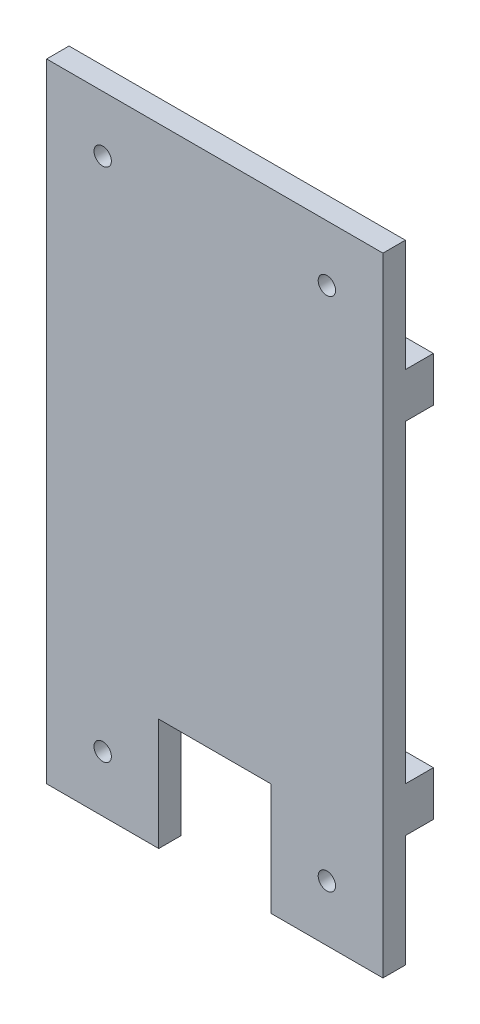
from build123d import *

# Parameters (mm, degrees)
SKETCH1_R           = 1.55
BOSS_EXTRUDE1_DEPTH = 4
SKETCH2_W           = 60
SKETCH2_H           = 8
BOSS_EXTRUDE2_DEPTH = 5


with BuildPart() as part:
    # Sketch1 → Boss-Extrude1 (new body)
    with BuildSketch(Plane.XY):
        Polygon((-30, 56), (-30, -56), (-10, -56), (-10, -36), (10, -36), (10, -56), (30, -56), (30, 56), align=None)
        with Locations((-20, -46)):
            Circle(SKETCH1_R, mode=Mode.SUBTRACT)
        with Locations((20, -46)):
            Circle(SKETCH1_R, mode=Mode.SUBTRACT)
        with Locations((-20, 46)):
            Circle(SKETCH1_R, mode=Mode.SUBTRACT)
        with Locations((20, 46)):
            Circle(SKETCH1_R, mode=Mode.SUBTRACT)
    extrude(amount=BOSS_EXTRUDE1_DEPTH)

    # Sketch2 → Boss-Extrude2 (add)
    with BuildSketch(Plane(origin=(0, 0, 0), x_dir=(-1, 0, 0), z_dir=(0, 0, -1))):
        with Locations((0, 32)):
            Rectangle(SKETCH2_W, SKETCH2_H)
        Polygon((30, -28), (-30, -28), (-30, -36), (-10, -36), (10, -36), (30, -36), align=None)
    extrude(amount=BOSS_EXTRUDE2_DEPTH)


solid = part.part
